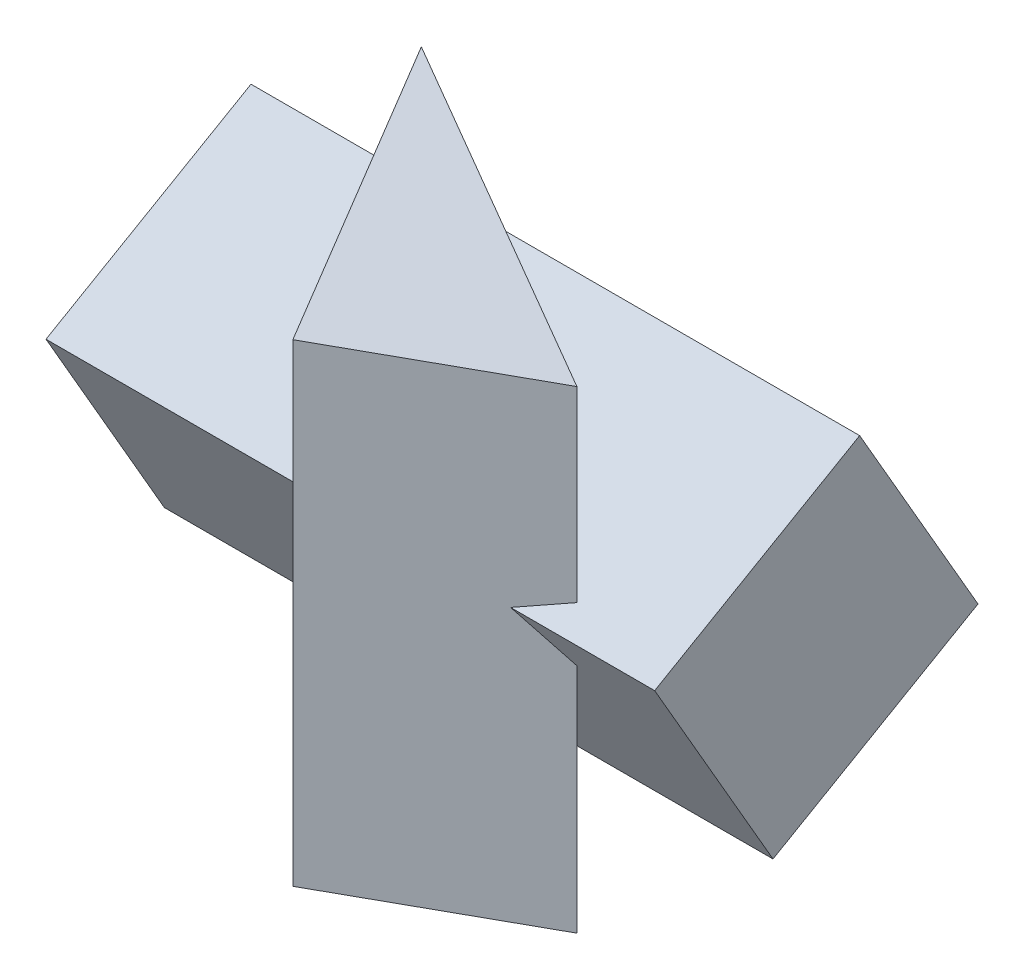
from build123d import *

# Parameters (mm, degrees)
TRIANGULAR_PRISM_DEPTH = 70
SQUARE_PRISM_DEPTH     = 90


with BuildPart() as part:
    # Sketch1 → Triangular prism (new body)
    with BuildSketch(Plane(origin=(0, 0, 0), x_dir=(1, 0, 0), z_dir=(0, 1, 0))):
        Polygon((-15, -14), (-70, 18), (-42, -29), align=None)
    extrude(amount=TRIANGULAR_PRISM_DEPTH)

    # Sketch2 → Square prism (add)
    with BuildSketch(Plane(origin=(0, 0, 0), x_dir=(0, 0, -1), z_dir=(1, 0, 0))):
        Polygon((12.810889132, 57.810889132), (-17.5, 40.310889132), (0, 10), (30.310889132, 27.5), align=None)
    extrude(amount=-SQUARE_PRISM_DEPTH)


solid = part.part
